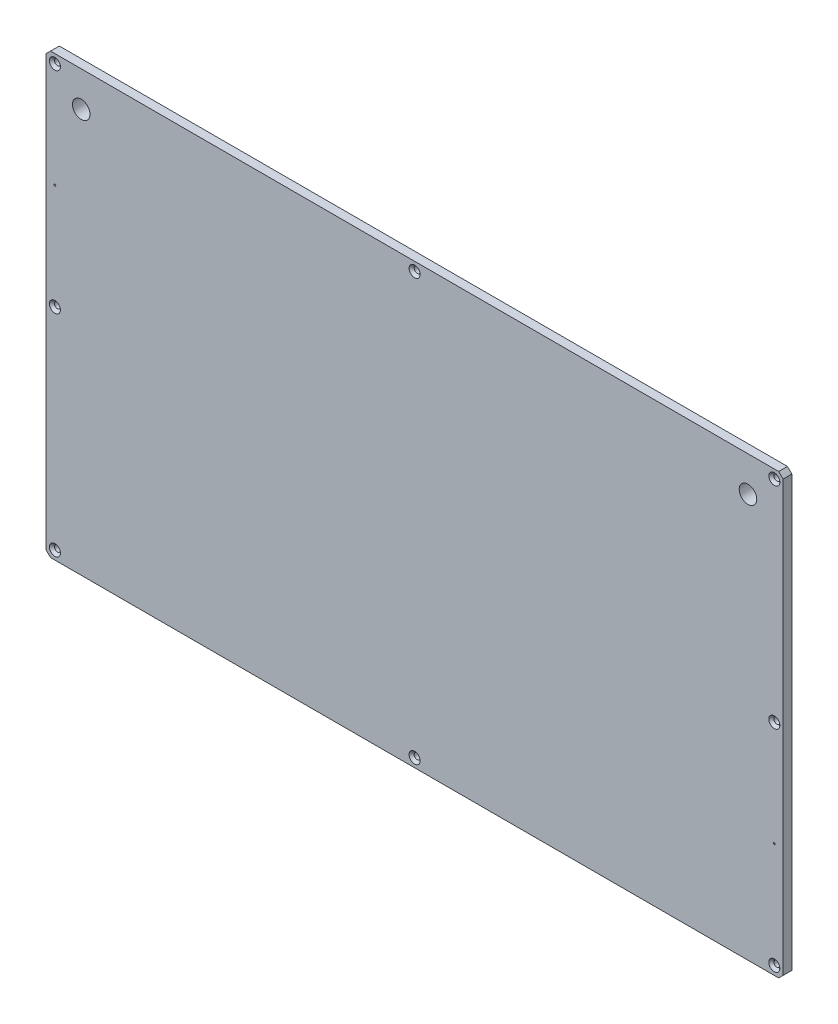
from build123d import *

# Parameters (mm, degrees)
SKETCH1_W                                       = 420
SKETCH1_H                                       = 250
BOSS_EXTRUDE1_DEPTH                             = 10
CHAMFER1_SIZE                                   = 2.5
CSK_FOR_M3_FLAT_HEAD_MACHINE_SCREW2_D           = 3.4
CSK_FOR_M3_FLAT_HEAD_MACHINE_SCREW2_DEPTH       = 15
CSK_FOR_M3_FLAT_HEAD_MACHINE_SCREW2_CSINK_D     = 6.3
CSK_FOR_M3_FLAT_HEAD_MACHINE_SCREW2_CSINK_ANGLE = 90
CSK_FOR_M3_FLAT_HEAD_MACHINE_SCREW2_TIP         = 1.021463052
SKETCH7_OUTSIDE_W                               = 519.776
SKETCH7_OUTSIDE_H                               = 349.776
SKETCH7_OUTSIDE_W_2                             = 400
SKETCH7_OUTSIDE_H_2                             = 230
CUT_EXTRUDE2_DEPTH                              = 5
CHAMFER2_SIZE                                   = 2.5
F_10_0MM_DOWEL_HOLE1_D                          = 10
F_1_0MM_DOWEL_HOLE1_D                           = 1


with BuildPart() as part:
    # Sketch1 → Boss-Extrude1 (new body)
    with BuildSketch(Plane.XY):
        with Locations((190, 105)):
            Rectangle(SKETCH1_W, SKETCH1_H)
    extrude(amount=-BOSS_EXTRUDE1_DEPTH)

    # Chamfer1
    chamfer1_edges = [part.edges().sort_by_distance(p)[0] for p in [
        (-20, 230, -5),
        (400, 230, -5),
        (400, -20, -5),
        (-20, -20, -5),
    ]]
    chamfer(chamfer1_edges, length=CHAMFER1_SIZE)

    # CSK for M3 Flat Head Machine Screw2
    with Locations(Plane.XY):
        with Locations((-15, 225), (190, 225), (395, 225), (395, -15), (190, -15), (-15, -15), (-15, 105), (395, 105)):
            CounterSinkHole(CSK_FOR_M3_FLAT_HEAD_MACHINE_SCREW2_D / 2, CSK_FOR_M3_FLAT_HEAD_MACHINE_SCREW2_CSINK_D / 2, depth=CSK_FOR_M3_FLAT_HEAD_MACHINE_SCREW2_DEPTH, counter_sink_angle=CSK_FOR_M3_FLAT_HEAD_MACHINE_SCREW2_CSINK_ANGLE)
            with Locations((0, 0, -(CSK_FOR_M3_FLAT_HEAD_MACHINE_SCREW2_DEPTH + CSK_FOR_M3_FLAT_HEAD_MACHINE_SCREW2_TIP / 2))):  # 118° drill point
                Cone(0, CSK_FOR_M3_FLAT_HEAD_MACHINE_SCREW2_D / 2, CSK_FOR_M3_FLAT_HEAD_MACHINE_SCREW2_TIP, mode=Mode.SUBTRACT)

    # Sketch7 outside → Cut-Extrude2 (cut)
    with BuildSketch(Plane(origin=(0, 0, -10), x_dir=(-1, 0, 0), z_dir=(0, 0, -1))):
        with Locations((-190, 105)):
            Rectangle(SKETCH7_OUTSIDE_W, SKETCH7_OUTSIDE_H)
        with Locations((-190, 105)):
            Rectangle(SKETCH7_OUTSIDE_W_2, SKETCH7_OUTSIDE_H_2, mode=Mode.SUBTRACT)
    extrude(amount=-CUT_EXTRUDE2_DEPTH, mode=Mode.SUBTRACT)

    # Chamfer2
    chamfer2_edges = [part.edges().sort_by_distance(p)[0] for p in [
        (-10, -10, -7.5),
        (390, -10, -7.5),
        (390, 220, -7.5),
        (-10, 220, -7.5),
    ]]
    chamfer(chamfer2_edges, length=CHAMFER2_SIZE)

    # Ø10.0mm Dowel Hole1 (through all)
    with Locations(Plane.XY):
        with Locations((0, 210)):
            f_10_0mm_dowel_hole1 = Hole(F_10_0MM_DOWEL_HOLE1_D / 2)

    # Mirror1: Ø10.0mm Dowel Hole1 across plane
    add(f_10_0mm_dowel_hole1.mirror(Plane.ZY.offset(-190)), mode=Mode.SUBTRACT)

    # Ø1.0mm Dowel Hole1 (through all)
    with Locations(Plane.XY):
        with Locations((-15, 165), (395, 45)):
            Hole(F_1_0MM_DOWEL_HOLE1_D / 2)


solid = part.part
